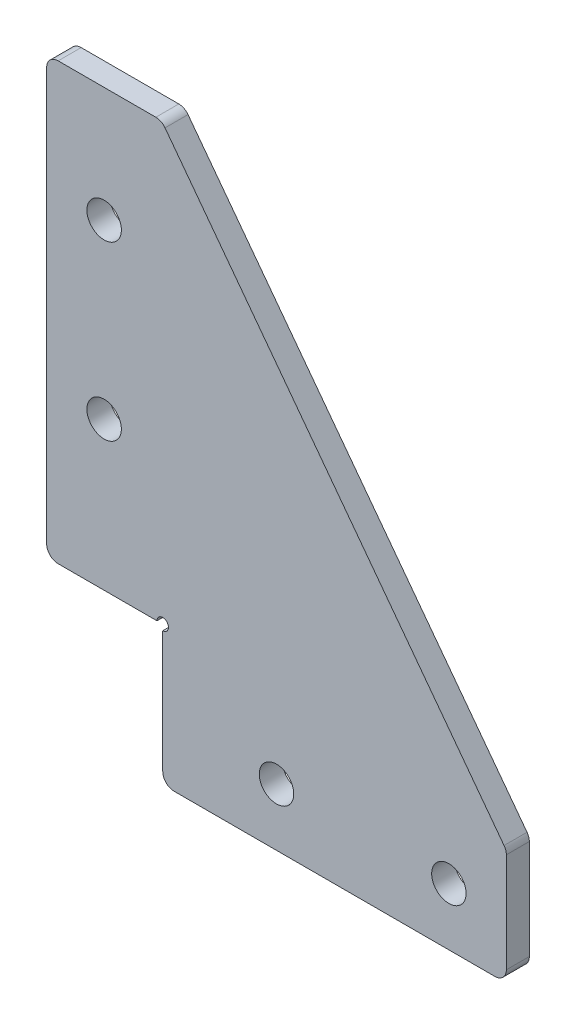
from build123d import *

# Parameters (mm, degrees)
SKETCH_1_R          = 1.5
EXTRUDE_1_DEPTH     = 2
SKETCH_3_R          = 0.5
CUT_EXTRUDE_3_DEPTH = 10
FILLET_1_R          = 1


with BuildPart() as part:
    # 草图1 → 凸台-拉伸1 (new body)
    with BuildSketch(Plane.XY):
        Polygon((5, 45), (-5, 45), (-5, 15), (-5, 7.1), (5.1, 7.1), (5.1, -5), (15, -5), (35, -5), (35, 5), align=None)
        with Locations((0, 20)):
            Circle(SKETCH_1_R, mode=Mode.SUBTRACT)
        with Locations((15, 0)):
            Circle(SKETCH_1_R, mode=Mode.SUBTRACT)
        with Locations((30, 0)):
            Circle(SKETCH_1_R, mode=Mode.SUBTRACT)
        with Locations((0, 35)):
            Circle(SKETCH_1_R, mode=Mode.SUBTRACT)
    extrude(amount=EXTRUDE_1_DEPTH)

    # 草图3 → 切除-拉伸3 (cut)
    with BuildSketch(Plane.XY.offset(2)):
        with Locations((5.1, 7.1)):
            Circle(SKETCH_3_R)
    extrude(amount=-CUT_EXTRUDE_3_DEPTH, mode=Mode.SUBTRACT)

    # 圆角1
    fillet_1_edges = [part.edges().sort_by_distance(p)[0] for p in [
        (-5, 45, 1),
        (5, 45, 1),
        (35, 5, 1),
        (35, -5, 1),
        (5.1, -5, 1),
        (-5, 7.1, 1),
    ]]
    fillet(fillet_1_edges, radius=FILLET_1_R)


solid = part.part
